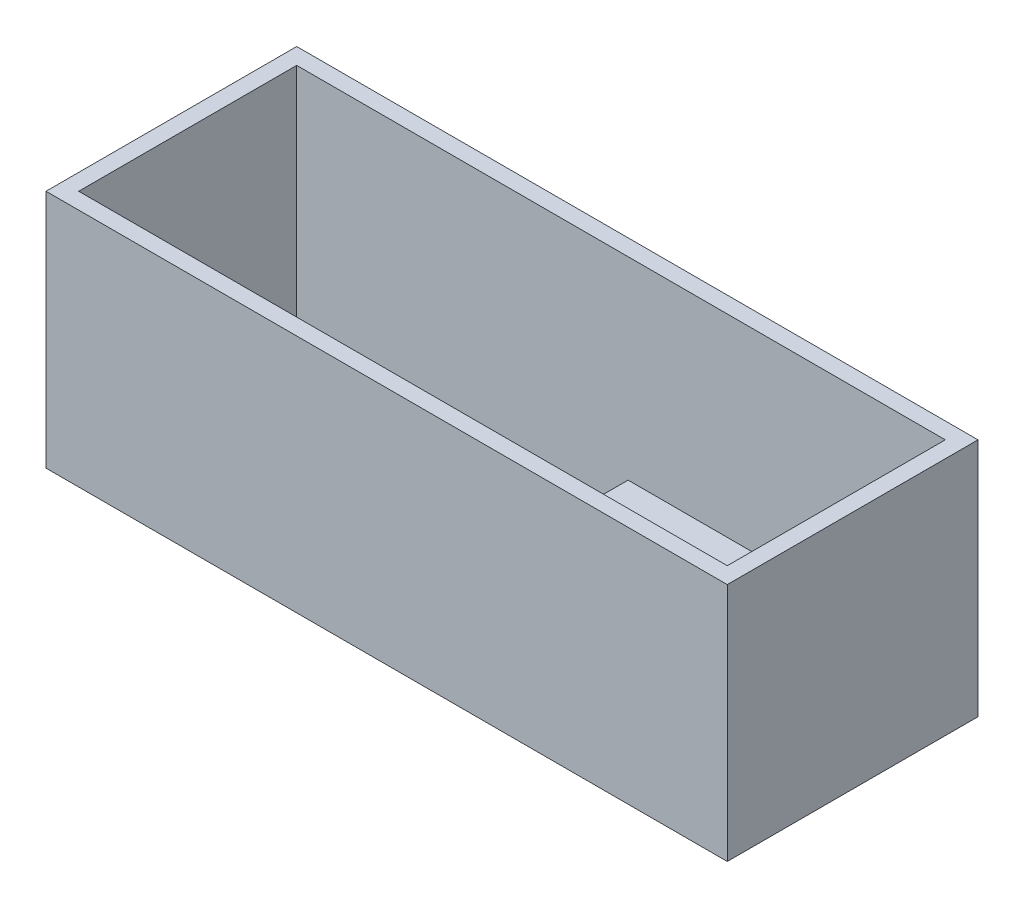
from build123d import *

# Parameters (mm, degrees)
SKETCH1_W           = 119
SKETCH1_H           = 40
BOSS_EXTRUDE1_DEPTH = 4
SKETCH2_W           = 125
SKETCH2_H           = 46
SKETCH2_W_2         = 119
SKETCH2_H_2         = 40
BOSS_EXTRUDE2_DEPTH = 44
SKETCH3_W           = 58.2
SKETCH3_H           = 40
BOSS_EXTRUDE3_DEPTH = 3
SKETCH4_W           = 28
SKETCH4_H           = 40
BOSS_EXTRUDE4_DEPTH = 1.5
SKETCH5_R           = 4
BOSS_EXTRUDE5_DEPTH = 12
SKETCH6_R           = 11.5
SKETCH6_R_2         = 4
CUT_EXTRUDE1_DEPTH  = 3
SKETCH7_R           = 11.5
SKETCH7_R_2         = 9
CUT_EXTRUDE2_DEPTH  = 1


with BuildPart() as part:
    # Sketch1 → Boss-Extrude1 (new body)
    with BuildSketch(Plane(origin=(0, 0, 0), x_dir=(1, 0, 0), z_dir=(0, 1, 0))):
        Rectangle(SKETCH1_W, SKETCH1_H)
    extrude(amount=BOSS_EXTRUDE1_DEPTH)

    # Sketch2 → Boss-Extrude2 (add)
    with BuildSketch(Plane(origin=(0, 0, 0), x_dir=(1, 0, 0), z_dir=(0, 1, 0))):
        Rectangle(SKETCH2_W, SKETCH2_H)
        Rectangle(SKETCH2_W_2, SKETCH2_H_2, mode=Mode.SUBTRACT)
    extrude(amount=BOSS_EXTRUDE2_DEPTH)

    # Sketch3 → Boss-Extrude3 (add)
    with BuildSketch(Plane(origin=(0, 4, 0), x_dir=(1, 0, 0), z_dir=(0, 1, 0))):
        with Locations((30.4, 0)):
            Rectangle(SKETCH3_W, SKETCH3_H)
    extrude(amount=BOSS_EXTRUDE3_DEPTH)

    # Sketch4 → Boss-Extrude4 (add)
    with BuildSketch(Plane(origin=(0, 7, 0), x_dir=(1, 0, 0), z_dir=(0, 1, 0))):
        with Locations((15.3, 0)):
            Rectangle(SKETCH4_W, SKETCH4_H)
    extrude(amount=BOSS_EXTRUDE4_DEPTH)

    # Sketch5 → Boss-Extrude5 (add)
    with BuildSketch(Plane.XZ):
        with Locations((39.5, 0)):
            Circle(SKETCH5_R)
    extrude(amount=BOSS_EXTRUDE5_DEPTH)

    # Sketch6 → Cut-Extrude1 (cut)
    with BuildSketch(Plane.XZ):
        with Locations((39.5, 0)):
            Circle(SKETCH6_R)
        with Locations((39.5, 0)):
            Circle(SKETCH6_R_2, mode=Mode.SUBTRACT)
    extrude(amount=-CUT_EXTRUDE1_DEPTH, mode=Mode.SUBTRACT)

    # Sketch7 → Cut-Extrude2 (cut)
    with BuildSketch(Plane.XZ.offset(-3)):
        with Locations((39.5, 0)):
            Circle(SKETCH7_R)
        with Locations((39.5, 0)):
            Circle(SKETCH7_R_2, mode=Mode.SUBTRACT)
    extrude(amount=-CUT_EXTRUDE2_DEPTH, mode=Mode.SUBTRACT)


solid = part.part
